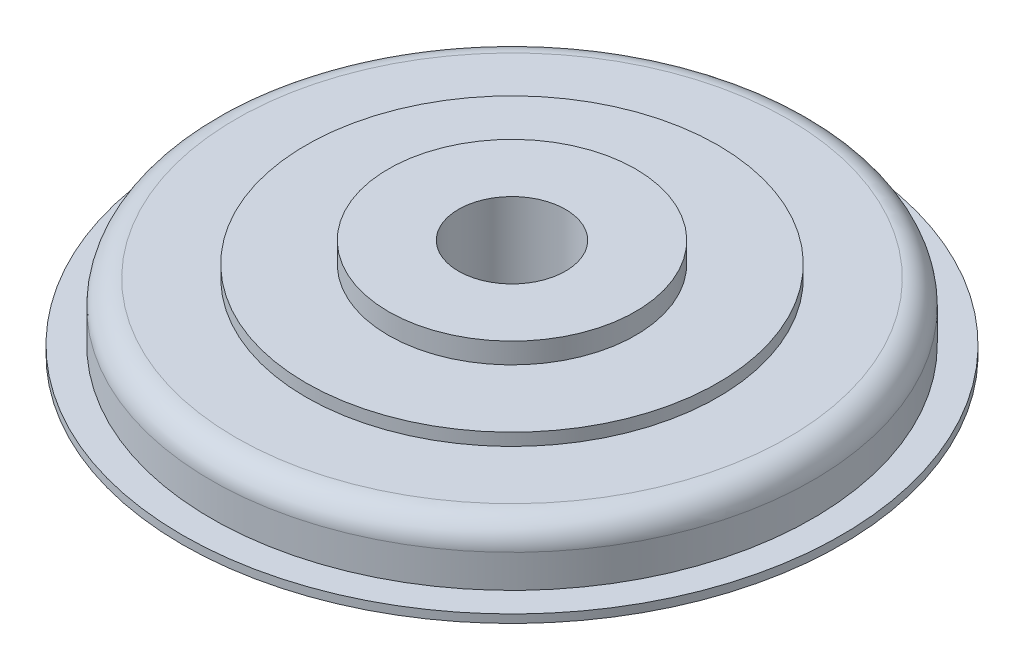
from build123d import *

# Parameters (mm, degrees)
SKETCH4_R           = 150
SKETCH4_R_2         = 65
BOSS_EXTRUDE3_DEPTH = 40
SKETCH5_R           = 50
CUT_EXTRUDE1_DEPTH  = 11
SKETCH6_R           = 65
CUT_EXTRUDE2_DEPTH  = 121


with BuildPart() as part:
    # Sketch1 → Revolve2 (revolve)
    with BuildSketch(Plane.XY):
        with BuildLine():
            Line((-200, 10), (-200, 0))
            Line((-200, 0), (200, 0))
            Line((200, 0), (200, 10))
            Line((200, 10), (165, 10))
            Line((165, 10), (165, 50))
            ThreePointArc((165, 50), (156.213203436, 71.213203436), (135, 80))
            Line((135, 80), (50, 80))
            Line((50, 80), (50, 95))
            Line((50, 95), (-50, 95))
            Line((-50, 95), (-50, 80))
            Line((-50, 80), (-135, 80))
            ThreePointArc((-135, 80), (-156.213203436, 71.213203436), (-165, 50))
            Line((-165, 50), (-165, 10))
            Line((-165, 10), (-200, 10))
        make_face()
    revolve(axis=Axis((-200, -16.726974685, 0), (0, 1, 0)))

    # Sketch4 → Boss-Extrude3 (add)
    with BuildSketch(Plane(origin=(0, 80, 0), x_dir=(1, 0, 0), z_dir=(0, 1, 0))):
        with Locations((-200, 0)):
            Circle(SKETCH4_R)
        with Locations((-200, 0)):
            Circle(SKETCH4_R_2, mode=Mode.SUBTRACT)
    extrude(amount=BOSS_EXTRUDE3_DEPTH)

    # Sketch5 → Cut-Extrude1 (cut, through all)
    with BuildSketch(Plane(origin=(0, 10, 0), x_dir=(1, 0, 0), z_dir=(0, 1, 0))):
        with Locations((-200, 0)):
            Circle(SKETCH5_R)
    extrude(amount=-CUT_EXTRUDE1_DEPTH, mode=Mode.SUBTRACT)

    # Sketch6 → Cut-Extrude2 (cut, through all)
    with BuildSketch(Plane(origin=(0, 120, 0), x_dir=(1, 0, 0), z_dir=(0, 1, 0))):
        with Locations((-200, 0)):
            Circle(SKETCH6_R)
    extrude(amount=-CUT_EXTRUDE2_DEPTH, mode=Mode.SUBTRACT)


solid = part.part
